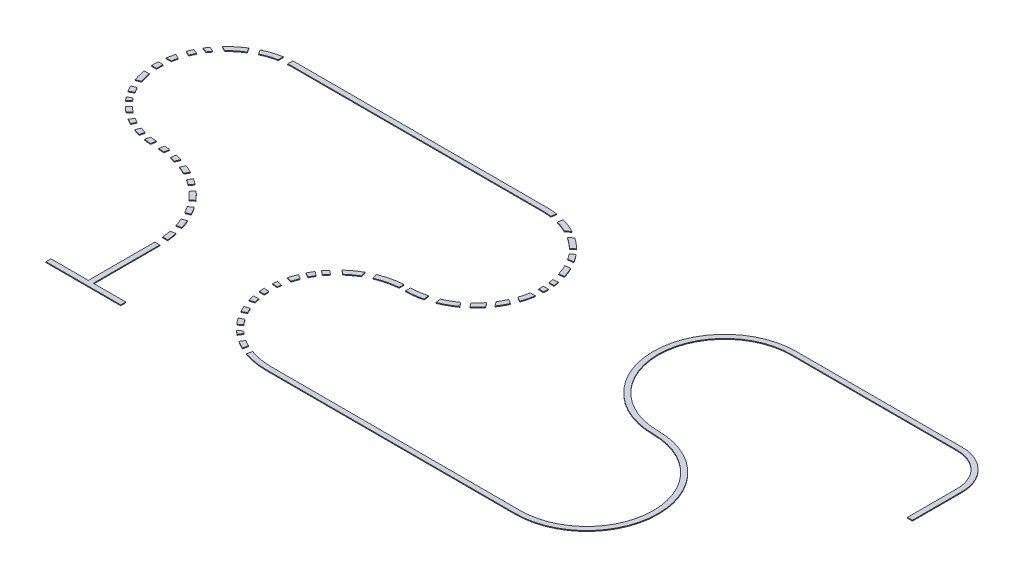
from build123d import *

# Parameters (mm, degrees)
BOSS_EXTRUDE1_DEPTH = 5
SKETCH4_W           = 50.071171354
SKETCH4_H           = 50
SKETCH4_W_2         = 98.852482053
SKETCH4_W_3         = 50
SKETCH4_H_2         = 92.982563048
SKETCH4_W_4         = 83.348309747
SKETCH4_H_3         = 44.028858289
SKETCH4_W_5         = 88.20752455
SKETCH4_H_4         = 45.721270681
SKETCH4_H_5         = 36.154436321
SKETCH4_W_6         = 37.981233151
SKETCH4_H_6         = 110.224755762
SKETCH4_W_7         = 61.418607013
SKETCH4_H_7         = 40.701467839
CUT_EXTRUDE1_DEPTH  = 5


with BuildPart() as part:
    # Sketch1 → Boss-Extrude1 (new body)
    with BuildSketch(Plane(origin=(0, 0, 0), x_dir=(1, 0, 0), z_dir=(0, 1, 0))):
        with BuildLine():
            Line((0, 0), (-450, 0))
            Line((-450, 0), (-450, 30))
            Line((-450, 30), (-225, 30))
            Line((-225, 30), (-225, 430))
            ThreePointArc((-225, 430), (-371.446609407, 783.553390593), (-725, 930))
            ThreePointArc((-725, 930), (-1155, 1360), (-725, 1790))
            Line((-725, 1790), (775, 1790))
            ThreePointArc((775, 1790), (1205, 1360), (775, 930))
            ThreePointArc((775, 930), (375, 530), (775, 130))
            Line((775, 130), (2275, 130))
            ThreePointArc((2275, 130), (2675, 530), (2275, 930))
            ThreePointArc((2275, 930), (1845, 1360), (2275, 1790))
            Line((2275, 1790), (3275, 1790))
            ThreePointArc((3275, 1790), (3437.634559673, 1722.634559673), (3505, 1560))
            Line((3505, 1560), (3505, 1260))
            Line((3505, 1260), (3475, 1260))
            Line((3475, 1260), (3475, 1560))
            ThreePointArc((3475, 1560), (3416.421356237, 1701.421356237), (3275, 1760))
            Line((3275, 1760), (2275, 1760))
            ThreePointArc((2275, 1760), (1875, 1360), (2275, 960))
            ThreePointArc((2275, 960), (2705, 530), (2275, 100))
            Line((2275, 100), (775, 100))
            ThreePointArc((775, 100), (345, 530), (775, 960))
            ThreePointArc((775, 960), (1175, 1360), (775, 1760))
            Line((775, 1760), (-725, 1760))
            ThreePointArc((-725, 1760), (-1125, 1360), (-725, 960))
            ThreePointArc((-725, 960), (-350.233405971, 804.766594029), (-195, 430))
            Line((-195, 430), (-195, 30))
            Line((-195, 30), (0, 30))
            Line((0, 30), (0, 0))
        make_face()
    extrude(amount=BOSS_EXTRUDE1_DEPTH)

    # Sketch4 → Cut-Extrude1 (cut)
    with BuildSketch(Plane(origin=(0, 5, 0), x_dir=(1, 0, 0), z_dir=(0, 1, 0))):
        with Locations((-220.035585677, 455)):
            Rectangle(SKETCH4_W, SKETCH4_H)
        Polygon((-247.188474093, 529.955150176), (-200.439605206, 539.625002237), (-210.567547493, 588.588506861), (-257.31641638, 578.9186548), align=None)
        Polygon((-220.766983648, 646.880718831), (-298.665069806, 615.915303697), (-317.134899869, 662.378895653), (-239.23681371, 693.344310787), align=None)
        Polygon((-363.741767941, 824.794338219), (-395.80094659, 785.480177007), (-434.55042482, 817.078878513), (-402.491246171, 856.393039726), align=None)
        Polygon((-434.184351384, 884.816093212), (-460.089800539, 838.901739795), (-503.636676324, 863.47142863), (-477.731227168, 909.385782047), align=None)
        Polygon((-610.735498117, 967.367265107), (-624.051426214, 882.39915636), (-673.448505917, 890.140507453), (-660.132577821, 975.1086162), align=None)
        Polygon((-908.357518486, 1038.289344925), (-960.917697927, 973.834812557), (-999.667176157, 1005.433514063), (-947.106996716, 1069.888046432), align=None)
        Polygon((-1049.813502759, 1195.830190441), (-1135.177183151, 1161.897112864), (-1153.647013214, 1208.36070482), (-1068.283332821, 1242.293782397), align=None)
        with Locations((-1136.938769741, 1315.667671524)):
            Rectangle(SKETCH4_W_2, SKETCH4_H)
        Polygon((-1031.164384599, 1418.264796924), (-1180.549120936, 1490.623203318), (-1158.752655618, 1535.622248859), (-1009.367919281, 1463.263842465), align=None)
        Polygon((-1101.734468704, 1625.997217821), (-1008.715929497, 1580.941254091), (-986.919464179, 1625.940299633), (-1079.938003386, 1670.996263362), align=None)
        Polygon((-973.024183627, 1755.128286079), (-924.080078571, 1677.15524304), (-881.731736387, 1703.737528763), (-930.675841444, 1781.710571803), align=None)
        with Locations((-779.132995596, 1760.303163305)):
            Rectangle(SKETCH4_W_3, SKETCH4_H_2)
        Polygon((-324.65285738, 701.595077245), (-278.6431416, 739.152254401), (-310.261069608, 777.886046217), (-356.270785387, 740.328869061), align=None)
        Polygon((-571.044263803, 951.369052576), (-593.988361843, 895.38380469), (-547.722908979, 876.423111892), (-524.778810939, 932.408359778), align=None)
        Polygon((-692.816093446, 981.864182708), (-704.174674753, 909.385782047), (-753.216347532, 917.071434912), (-741.857766224, 989.549835573), align=None)
        Polygon((-778.7230301, 989.549835573), (-795.057447633, 917.071434912), (-836.570149923, 926.427129932), (-820.235732391, 998.905530593), align=None)
        Polygon((-849.20143016, 1005.433514063), (-883.989276423, 926.427129932), (-927.579819916, 945.620782979), (-892.791973653, 1024.627167111), align=None)
        Polygon((-1030.362287409, 1038.289344925), (-989.374479587, 1081.104380401), (-1019.79162057, 1110.223401681), (-1060.779428392, 1067.408366205), align=None)
        Polygon((-1076.278315849, 1096.180715001), (-1030.362287409, 1121.785262386), (-1051.284782748, 1159.305077776), (-1097.200811189, 1133.700530391), align=None)
        with Locations((-1138.874966062, 1401.918699315)):
            Rectangle(SKETCH4_W_4, SKETCH4_H_3)
        Polygon((-1138.874966062, 1560.859230554), (-1060.779428392, 1531.547716645), (-1046.510017829, 1569.566131307), (-1124.6055555, 1598.877645216), align=None)
        Polygon((845.802481412, 1822.912973307), (820.576952761, 1703.737528763), (870.823807957, 1693.101919303), (896.049336608, 1812.277363847), align=None)
        Polygon((913.582280507, 1693.091230503), (993.44677714, 1754.078474801), (1021.194441354, 1717.742134954), (941.329944721, 1656.754890656), align=None)
        Polygon((1030.019805562, 1625.833750496), (1091.710938082, 1672.943196228), (1116.460796919, 1640.532566096), (1054.769664398, 1593.423120364), align=None)
        Polygon((1085.650881088, 1580.928385662), (1162.989301907, 1591.228244467), (1169.042258034, 1545.778488603), (1091.703837215, 1535.478629798), align=None)
        Polygon((1131.596834483, 1476.036241659), (1202.619302108, 1485.494947704), (1209.005838014, 1437.540445528), (1137.983370389, 1428.081739483), align=None)
        with Locations((1183.72294378, 1317.807036184)):
            Rectangle(SKETCH4_W_5, SKETCH4_H_4)
        with Locations((1183.72294378, 1386.930675743)):
            Rectangle(SKETCH4_W_5, SKETCH4_H_5)
        Polygon((1125.930261484, 1252.8070903), (1209.80671743, 1203.457027303), (1188.401190367, 1167.075721209), (1104.524734422, 1216.425784206), align=None)
        Polygon((1091.080516801, 1174.212188942), (1144.816591891, 1103.843300539), (1114.444547521, 1080.650175084), (1060.708472432, 1151.019063488), align=None)
        Polygon((1031.299337888, 1079.774934699), (1076.270058077, 1020.884522901), (1041.65038083, 994.4477606), (996.679660641, 1053.338172398), align=None)
        Polygon((927.706309082, 1024.189510686), (941.816528502, 918.240282838), (886.963818085, 910.935049988), (872.853598666, 1016.884277836), align=None)
        with Locations((765.021540725, 939.928471093)):
            Rectangle(SKETCH4_W_6, SKETCH4_H_6)
        Polygon((600.645599307, 963.909663912), (631.948970968, 856.393039726), (582.722592387, 842.060822398), (551.419220726, 949.577446583), align=None)
        Polygon((462.910764002, 863.47142863), (533.030316521, 808.699344521), (501.179962883, 767.924329639), (431.060410364, 822.696413748), align=None)
        Polygon((409.66850832, 795.310371694), (481.562468884, 739.152254401), (464.422175216, 717.209147039), (392.528214653, 773.367264332), align=None)
        Polygon((365.802040078, 739.152254401), (443.658231764, 693.344310787), (426.174484383, 663.628547972), (348.318292697, 709.436491585), align=None)
        Polygon((337.69727736, 646.880718831), (404.730135921, 632.692063604), (394.444436499, 584.098322798), (327.411577939, 598.286978025), align=None)
        Polygon((327.411577939, 570.131685947), (394.444436499, 562.406537552), (388.830184952, 513.690408019), (321.797326392, 521.415556414), align=None)
        with Locations((358.120881446, 467.171334186)):
            Rectangle(SKETCH4_W_7, SKETCH4_H_7)
        Polygon((348.318292697, 406.820881872), (404.730135921, 423.245140985), (418.916489504, 374.519755638), (362.50464628, 358.095496526), align=None)
        Polygon((376.524214309, 317.523776591), (434.916358074, 347.426411747), (457.742141298, 302.853536861), (399.349997533, 272.950901704), align=None)
        Polygon((434.916358074, 237.330345945), (481.562468884, 272.950901704), (509.186637122, 236.776283281), (462.540526311, 201.155727521), align=None)
        Polygon((495.374553003, 181.100695378), (523.24219505, 228.465154683), (568.150632, 202.042552922), (540.282989952, 154.678093618), align=None)
        Polygon((600.645599307, 186.35994511), (587.997350788, 126.604581372), (632.061343337, 117.277680929), (644.709591857, 177.033044667), align=None)
    extrude(amount=-CUT_EXTRUDE1_DEPTH, mode=Mode.SUBTRACT)


solid = part.part
